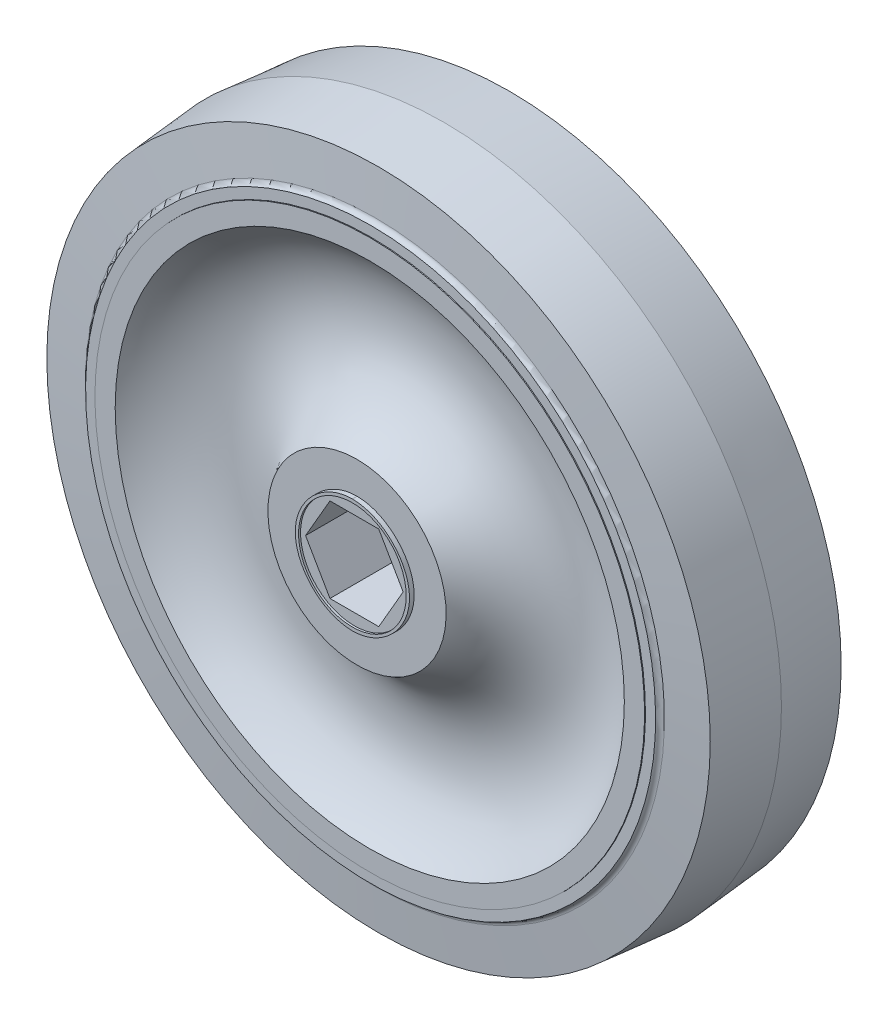
from build123d import *

# Parameters (mm, degrees)
BOSS_EXTRUDE1_DEPTH = 0.70005
BOSS_EXTRUDE1_TAPER = 0.500000001
SKETCH3_R           = 8.603491183
BOSS_EXTRUDE2_DEPTH = 0.70005
BOSS_EXTRUDE2_TAPER = 0.5
CUT_EXTRUDE1_REACH  = 29.288
CHAMFER1_SIZE       = 0.3


with BuildPart() as part:
    # Sketch1 → Revolve1 (revolve)
    with BuildSketch(Plane.XZ):
        with BuildLine():
            Line((13.415893662, 13.0937), (0, 13.0937))
            Line((0, 13.0937), (0, -13.0937))
            Line((0, -13.0937), (13.415893662, -13.0937))
            ThreePointArc((13.415893662, -13.0937), (25.305885072, -4.804656146), (38.324568616, -11.176))
            Line((38.324568616, -11.176), (41.373689588, -11.176))
            Line((41.373689588, -11.176), (41.626614995, -6.349895721))
            Line((41.626614995, -6.349895721), (41.6306, -6.35))
            Line((41.6306, -6.35), (41.384335845, -11.049))
            Line((41.384335845, -11.049), (42.908335845, -11.049))
            ThreePointArc((42.908335845, -11.049), (43.141334556, -10.611106234), (43.59449453, -10.409400044))
            Line((43.59449453, -10.409400044), (49.937849228, -9.854428419))
            Line((49.937849228, -9.854428419), (50.8, 0))
            Line((50.8, 0), (49.937849228, 9.854428419))
            Line((49.937849228, 9.854428419), (43.59449453, 10.409400044))
            ThreePointArc((43.59449453, 10.409400044), (43.141334556, 10.611106234), (42.908335845, 11.049))
            Line((42.908335845, 11.049), (41.384335845, 11.049))
            Line((41.384335845, 11.049), (41.630594535, 6.350104279))
            Line((41.630594535, 6.350104279), (41.62660953, 6.35))
            Line((41.62660953, 6.35), (41.373689588, 11.176))
            Line((41.373689588, 11.176), (38.324568616, 11.176))
            ThreePointArc((38.324568616, 11.176), (25.305885072, 4.804656146), (13.415893662, 13.0937))
        make_face()
    revolve(axis=Axis((0, 0, 13.0937), (0, 0, -1)))

    # Sketch2 → Boss-Extrude1 (add)
    with BuildSketch(Plane(origin=(0, 0, 13.0937), x_dir=(-1, 0, 0), z_dir=(0, 0, -1))):
        with BuildLine():
            add(Edge.make_bspline(
                [(0, -8.603491183), (4.50477745, -8.603491183), (8.603491183, -4.50477745), (8.603491183, 4.50477745), (4.50477745, 8.603491183), (0, 8.603491183)],
                knots=[0, 0, 0, 0, 0.5, 0.5, 1, 1, 1, 1], degree=3))
            add(Edge.make_bspline(
                [(0, 8.603491183), (-4.50477745, 8.603491183), (-8.603491183, 4.50477745), (-8.603491183, -4.50477745), (-4.50477745, -8.603491183), (0, -8.603491183)],
                knots=[0, 0, 0, 0, 0.5, 0.5, 1, 1, 1, 1], degree=3))
        make_face()
    extrude(amount=-BOSS_EXTRUDE1_DEPTH, taper=BOSS_EXTRUDE1_TAPER)

    # Sketch3 → Boss-Extrude2 (add)
    with BuildSketch(Plane.XY.offset(-13.0937)):
        Circle(SKETCH3_R)
    extrude(amount=-BOSS_EXTRUDE2_DEPTH, taper=BOSS_EXTRUDE2_TAPER)

    # Sketch4 → Hole1 (revolve, cut)
    with BuildSketch(Plane(origin=(0, 0, 13.79375), x_dir=(0, -1, 0), z_dir=(1, 0, 0))):
        Polygon((0, 0), (0, 0.3), (8.1, 0.3), (8.10261806, 0), align=None)
    revolve(axis=Axis((0, 0, -96.20625), (0, 0, 1)), mode=Mode.SUBTRACT)

    # Sketch6 → Hole2 (revolve, cut)
    with BuildSketch(Plane(origin=(0, 0, -13.79375), x_dir=(0, 1, 0), z_dir=(1, 0, 0))):
        Polygon((0, 0), (0, 0.3), (8.1, 0.3), (8.10261806, 0), align=None)
    revolve(axis=Axis((0, 0, 96.20625), (0, 0, -1)), mode=Mode.SUBTRACT)

    # Sketch8 → Cut-Extrude1 (cut, up to next)
    with BuildSketch(Plane(origin=(0, 0, -13.49375), x_dir=(-1, 0, 0), z_dir=(0, 0, -1)), mode=Mode.PRIVATE) as cut_extrude1_sk1:
        Polygon((-7.347013116, 0), (-3.673506558, -6.3627), (3.673506558, -6.3627), (7.347013116, 0), (3.673506558, 6.3627), (-3.673506558, 6.3627), align=None)
    cut_extrude1_tool1 = extrude(cut_extrude1_sk1.sketch, amount=-CUT_EXTRUDE1_REACH, mode=Mode.PRIVATE) & part.part
    add(cut_extrude1_tool1.solids().sort_by_distance((0, 0, -13.49375))[0], mode=Mode.SUBTRACT)

    # Chamfer1
    chamfer1_edges = [part.edges().sort_by_distance(p)[0] for p in [
        (5.510259837, 3.18135, -13.49375),
        (5.510259837, -3.18135, -13.49375),
        (0, -6.3627, -13.49375),
        (-5.510259837, -3.18135, -13.49375),
        (-5.510259837, 3.18135, -13.49375),
        (0, 6.3627, -13.49375),
    ]]
    chamfer(chamfer1_edges, length=CHAMFER1_SIZE)


solid = part.part
